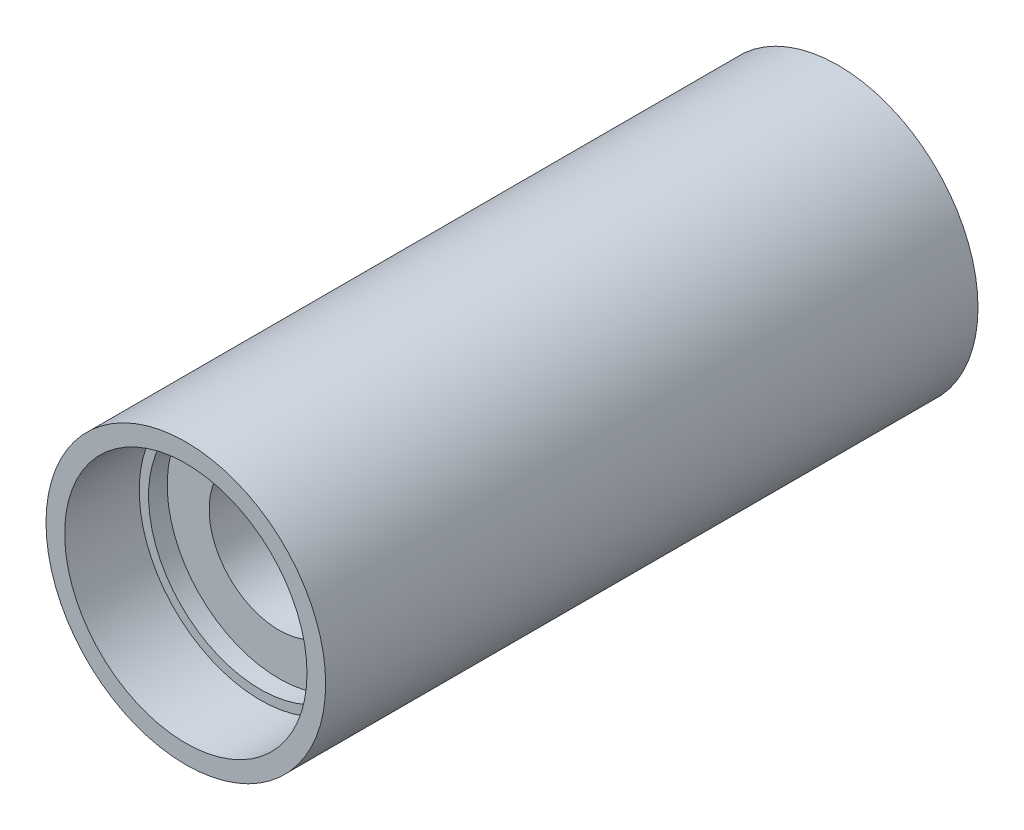
from build123d import *


with BuildPart() as part:
    # Эскиз1 → Повернуть1 (revolve)
    with BuildSketch(Plane(origin=(0, 0, 0), x_dir=(1, 0, 0), z_dir=(0, 1, 0))):
        Polygon((15, 0), (7.5, 0), (7.5, -24.990014613), (12, -24.990014613), (12, -26.990014613), (13, -26.990014613), (13, -34.990014613), (15, -34.990014613), align=None)
    revolve(axis=Axis((0, 0, 1005.29300139), (0, 0, -1)))

    # Зеркальное отражение1: part across plane


with BuildPart() as part_1:
    add(part.part)
    add(part.part.mirror(Plane(origin=(15, 0, 0), x_dir=(1, 0, 0), z_dir=(0, 0, -1))))


solid = part_1.part
